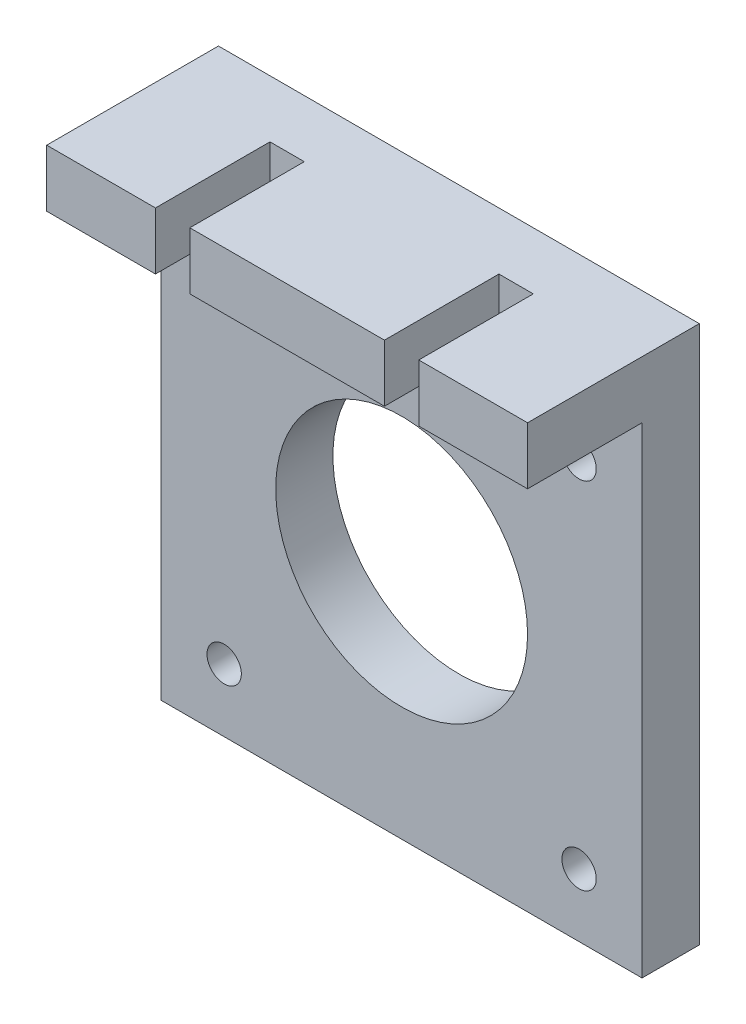
from build123d import *

# Parameters (mm, degrees)
SKETCH1_W           = 42
SKETCH1_H           = 47
SKETCH1_R           = 1.5
SKETCH1_R_2         = 11
BOSS_EXTRUDE1_DEPTH = 5
SKETCH2_W           = 42
SKETCH2_H           = 5
BOSS_EXTRUDE2_DEPTH = 10
SKETCH3_W           = 3
SKETCH3_H           = 10
CUT_EXTRUDE1_DEPTH  = 6


with BuildPart() as part:
    # Sketch1 → Boss-Extrude1 (new body)
    with BuildSketch(Plane.XY):
        with Locations((0, 2.5)):
            Rectangle(SKETCH1_W, SKETCH1_H)
        with Locations((-15.5, -15.5)):
            Circle(SKETCH1_R, mode=Mode.SUBTRACT)
        with Locations((15.5, -15.5)):
            Circle(SKETCH1_R, mode=Mode.SUBTRACT)
        Circle(SKETCH1_R_2, mode=Mode.SUBTRACT)
        with Locations((-15.5, 15.5)):
            Circle(SKETCH1_R, mode=Mode.SUBTRACT)
        with Locations((15.5, 15.5)):
            Circle(SKETCH1_R, mode=Mode.SUBTRACT)
    extrude(amount=BOSS_EXTRUDE1_DEPTH)

    # Sketch2 → Boss-Extrude2 (add)
    with BuildSketch(Plane.XY.offset(5)):
        with Locations((0, 23.5)):
            Rectangle(SKETCH2_W, SKETCH2_H)
    extrude(amount=BOSS_EXTRUDE2_DEPTH)

    # Sketch3 → Cut-Extrude1 (cut, through all)
    with BuildSketch(Plane.XZ.offset(-21)):
        with Locations((-10, 10)):
            Rectangle(SKETCH3_W, SKETCH3_H)
        with Locations((10, 10)):
            Rectangle(SKETCH3_W, SKETCH3_H)
    extrude(amount=-CUT_EXTRUDE1_DEPTH, mode=Mode.SUBTRACT)


solid = part.part
